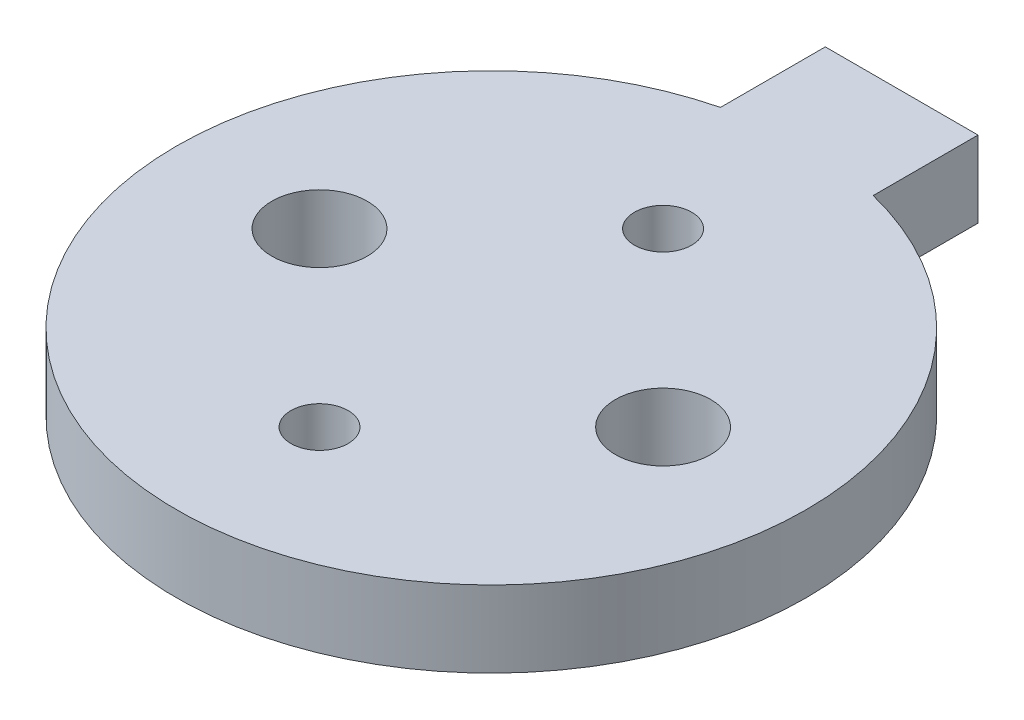
from build123d import *

# Parameters (mm, degrees)
SKETCH1_R           = 33
BOSS_EXTRUDE1_DEPTH = 8
SKETCH2_W           = 16
SKETCH2_H           = 10.984378813
BOSS_EXTRUDE2_DEPTH = 8
SKETCH3_R           = 3
SKETCH3_R_2         = 5
CUT_EXTRUDE1_DEPTH  = 9


with BuildPart() as part:
    # Sketch1 → Boss-Extrude1 (new body)
    with BuildSketch(Plane(origin=(0, 0, 0), x_dir=(1, 0, 0), z_dir=(0, 1, 0))):
        Circle(SKETCH1_R)
    extrude(amount=BOSS_EXTRUDE1_DEPTH)

    # Sketch2 → Boss-Extrude2 (add)
    with BuildSketch(Plane(origin=(0, 8, 0), x_dir=(1, 0, 0), z_dir=(0, 1, 0))):
        with Locations((0, 37.507810593)):
            Rectangle(SKETCH2_W, SKETCH2_H)
    extrude(amount=-BOSS_EXTRUDE2_DEPTH)

    # Sketch3 → Cut-Extrude1 (cut, through all)
    with BuildSketch(Plane(origin=(0, 8, 0), x_dir=(1, 0, 0), z_dir=(0, 1, 0))):
        with Locations((0, 18)):
            Circle(SKETCH3_R)
        with Locations((-18, 0)):
            Circle(SKETCH3_R_2)
        with Locations((0, -18)):
            Circle(SKETCH3_R)
        with Locations((18, 0)):
            Circle(SKETCH3_R_2)
    extrude(amount=-CUT_EXTRUDE1_DEPTH, mode=Mode.SUBTRACT)


solid = part.part
